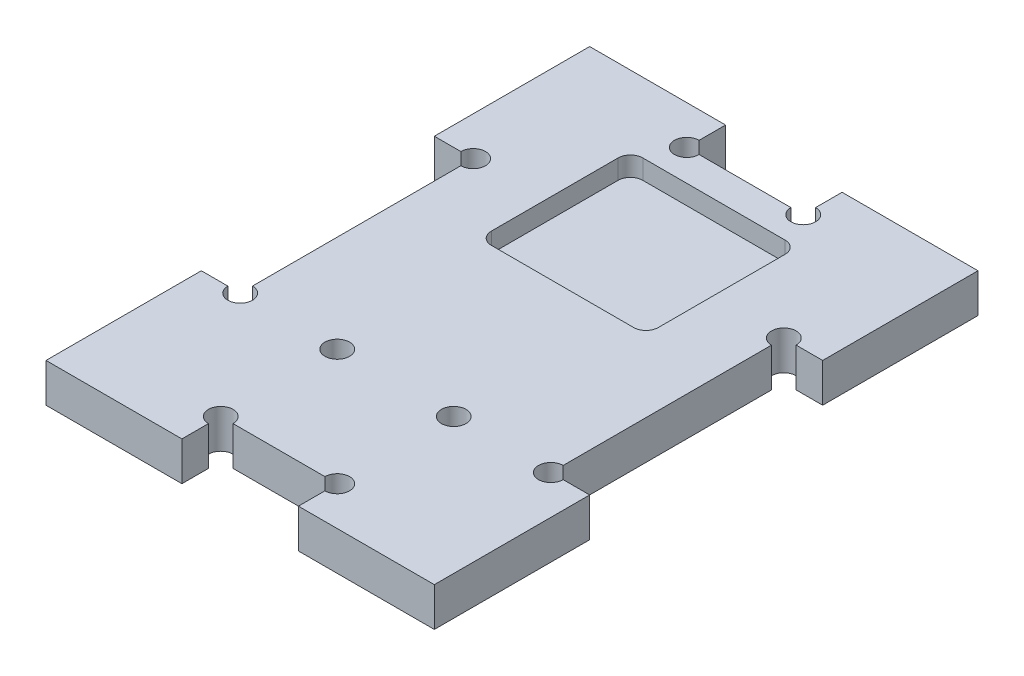
from build123d import *

# Parameters (mm, degrees)
SKETCH1_W               = 50
SKETCH1_H               = 70
BOSS_EXTRUDE1_DEPTH     = 5
CUT_EXTRUDE2_START      = -2.5
CUT_EXTRUDE2_DEPTH      = 2.5
SKETCH5_W               = 5
SKETCH5_H               = 30
SKETCH5_W_2             = 15
SKETCH5_H_2             = 5
CUT_EXTRUDE3_DEPTH      = 1
CUT_EXTRUDE3_DEPTH_BACK = 6
SKETCH6_R               = 1.5875
CUT_EXTRUDE4_DEPTH      = 6


with BuildPart() as part:
    # Sketch1 → Boss-Extrude1 (new body)
    with BuildSketch(Plane(origin=(0, 0, 0), x_dir=(1, 0, 0), z_dir=(0, 1, 0))):
        with Locations((25, 35)):
            Rectangle(SKETCH1_W, SKETCH1_H)
    extrude(amount=BOSS_EXTRUDE1_DEPTH)

    # Sketch4 → Cut-Extrude2 (cut)
    with BuildSketch(Plane.XZ.offset(CUT_EXTRUDE2_START)):
        with BuildLine():
            Line((34.1625, -61), (15.8375, -61))
            ThreePointArc((15.8375, -61), (14.714967985, -60.535032015), (14.25, -59.4125))
            Line((14.25, -59.4125), (14.25, -43.0875))
            ThreePointArc((14.25, -43.0875), (14.714967985, -41.964967985), (15.8375, -41.5))
            Line((15.8375, -41.5), (34.1625, -41.5))
            ThreePointArc((34.1625, -41.5), (35.285032015, -41.964967985), (35.75, -43.0875))
            Line((35.75, -43.0875), (35.75, -59.4125))
            ThreePointArc((35.75, -59.4125), (35.285032015, -60.535032015), (34.1625, -61))
        make_face()
    extrude(amount=-CUT_EXTRUDE2_DEPTH, mode=Mode.SUBTRACT)

    # Sketch5 → Cut-Extrude3 (cut, two sides)
    with BuildSketch(Plane(origin=(0, 5, 0), x_dir=(1, 0, 0), z_dir=(0, 1, 0))) as cut_extrude3_sk:
        with Locations((2.5, 35)):
            Rectangle(SKETCH5_W, SKETCH5_H)
        with Locations((25, 67.5)):
            Rectangle(SKETCH5_W_2, SKETCH5_H_2)
        with Locations((47.5, 35)):
            Rectangle(SKETCH5_W, SKETCH5_H)
        with Locations((25, 2.5)):
            Rectangle(SKETCH5_W_2, SKETCH5_H_2)
    extrude(amount=CUT_EXTRUDE3_DEPTH, mode=Mode.SUBTRACT)
    extrude(cut_extrude3_sk.sketch, amount=-CUT_EXTRUDE3_DEPTH_BACK, mode=Mode.SUBTRACT)

    # Sketch6 → Cut-Extrude4 (cut, through all)
    with BuildSketch(Plane(origin=(0, 5, 0), x_dir=(1, 0, 0), z_dir=(0, 1, 0))):
        with Locations((5, 20)):
            Circle(SKETCH6_R)
        with Locations((5, 50)):
            Circle(SKETCH6_R)
        with Locations((17.5, 65)):
            Circle(SKETCH6_R)
        with Locations((32.5, 65)):
            Circle(SKETCH6_R)
        with Locations((45, 50)):
            Circle(SKETCH6_R)
        with Locations((45, 20)):
            Circle(SKETCH6_R)
        with Locations((32.5, 5)):
            Circle(SKETCH6_R)
        with Locations((17.5, 5)):
            Circle(SKETCH6_R)
        with Locations((17.5, 20)):
            Circle(SKETCH6_R)
        with Locations((32.5, 20)):
            Circle(SKETCH6_R)
    extrude(amount=-CUT_EXTRUDE4_DEPTH, mode=Mode.SUBTRACT)


solid = part.part
